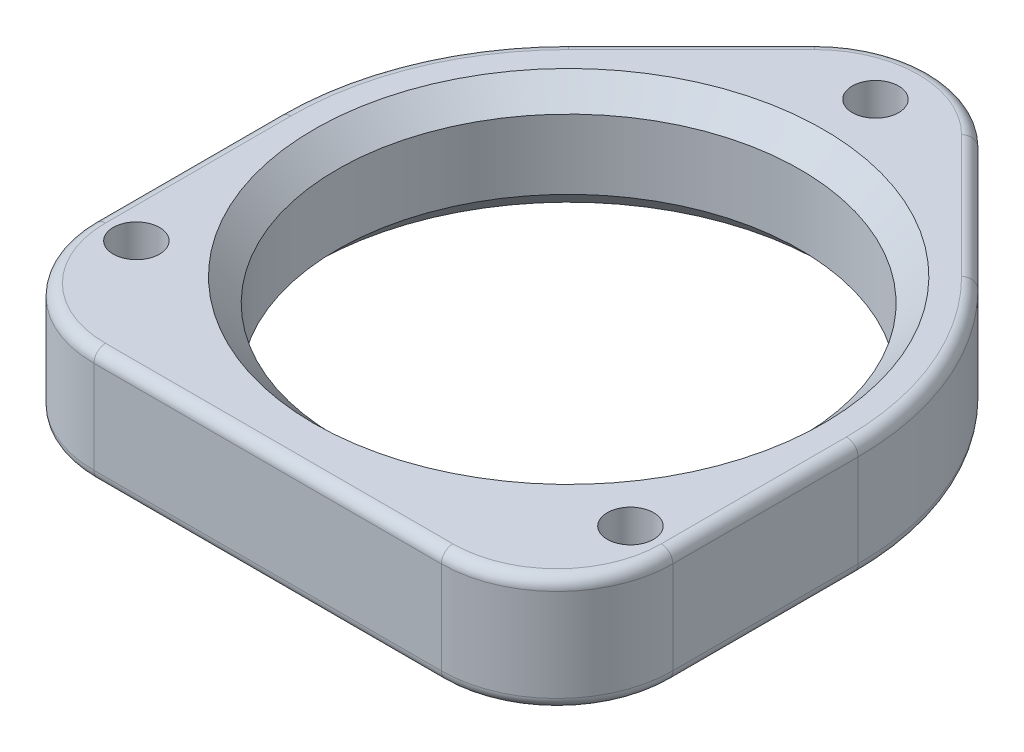
from build123d import *

# Parameters (mm, degrees)
SKETCH1_R           = 25
SKETCH1_R_2         = 20
BOSS_EXTRUDE1_DEPTH = 10
BOSS_EXTRUDE2_DEPTH = 10
BOSS_EXTRUDE3_DEPTH = 10
FILLET1_R           = 10
SKETCH2_R           = 2
CUT_EXTRUDE1_DEPTH  = 10
CHAMFER1_SIZE       = 2
FILLET2_R           = 10
CHAMFER2_SIZE       = 2
FILLET3_R           = 1


with BuildPart() as part:
    # Sketch1 → Boss-Extrude1 (new body)
    with BuildSketch(Plane(origin=(0, 0, 0), x_dir=(1, 0, 0), z_dir=(0, 1, 0))):
        Circle(SKETCH1_R)
        Circle(SKETCH1_R_2, mode=Mode.SUBTRACT)
    extrude(amount=BOSS_EXTRUDE1_DEPTH)

    # Sketch3 → Boss-Extrude2 (add)
    with BuildSketch(Plane(origin=(0, 10, 0), x_dir=(1, 0, 0), z_dir=(0, 1, 0))):
        with BuildLine():
            Line((-25, -26), (25, -26))
            Line((25, -26), (25, 0))
            ThreePointArc((25, 0), (0, -25), (-25, 0))
            Line((-25, 0), (-25, -26))
        make_face()
    extrude(amount=-BOSS_EXTRUDE2_DEPTH)

    # Sketch4 → Boss-Extrude3 (add)
    with BuildSketch(Plane(origin=(0, 10, 0), x_dir=(1, 0, 0), z_dir=(0, 1, 0))):
        with BuildLine():
            Line((0, 35.355339059), (-17.67766953, 17.67766953))
            ThreePointArc((-17.67766953, 17.67766953), (0, 25), (17.67766953, 17.67766953))
            Line((17.67766953, 17.67766953), (0, 35.355339059))
        make_face()
    extrude(amount=-BOSS_EXTRUDE3_DEPTH)

    # Fillet1
    fillet1_edges = [part.edges().sort_by_distance(p)[0] for p in [
        (0, 5, -35.355339059),
    ]]
    fillet(fillet1_edges, radius=FILLET1_R)

    # Sketch2 → Cut-Extrude1 (cut)
    with BuildSketch(Plane(origin=(0, 10, 0), x_dir=(1, 0, 0), z_dir=(0, 1, 0))):
        with Locations((-21.335, -16)):
            Circle(SKETCH2_R)
        with Locations((0, 26.5)):
            Circle(SKETCH2_R)
        with Locations((21.335, -16)):
            Circle(SKETCH2_R)
    extrude(amount=-CUT_EXTRUDE1_DEPTH, mode=Mode.SUBTRACT)

    # Chamfer1
    chamfer1_edges = [part.edges().sort_by_distance(p)[0] for p in [
        (-20, 0, 0),
    ]]
    chamfer(chamfer1_edges, length=CHAMFER1_SIZE)

    # Fillet2
    fillet2_edges = [part.edges().sort_by_distance(p)[0] for p in [
        (-25, 5, 26),
        (25, 5, 26),
    ]]
    fillet(fillet2_edges, radius=FILLET2_R)

    # Chamfer2
    chamfer2_edges = [part.edges().sort_by_distance(p)[0] for p in [
        (-20, 10, 0),
    ]]
    chamfer(chamfer2_edges, length=CHAMFER2_SIZE)

    # Fillet3
    fillet3_edges = [part.edges().sort_by_distance(p)[0] for p in [
        (-25, 0, 8),
        (-25, 10, 8),
        (23.096988313, 0, -9.567085809),
        (-23.096988313, 0, -9.567085809),
        (-23.096988313, 10, -9.567085809),
        (-12.374368671, 10, -22.980970389),
        (-12.374368671, 0, -22.980970389),
        (12.374368671, 10, -22.980970389),
        (12.374368671, 0, -22.980970389),
        (0, 10, -31.213203436),
        (0, 0, -31.213203436),
        (23.096988313, 10, -9.567085809),
        (0, 10, 26),
        (0, 0, 26),
        (25, 10, 8),
        (-22.071067812, 10, 23.071067812),
        (22.071067812, 10, 23.071067812),
        (25, 0, 8),
        (-22.071067812, 0, 23.071067812),
        (22.071067812, 0, 23.071067812),
    ]]
    fillet(fillet3_edges, radius=FILLET3_R)


solid = part.part
